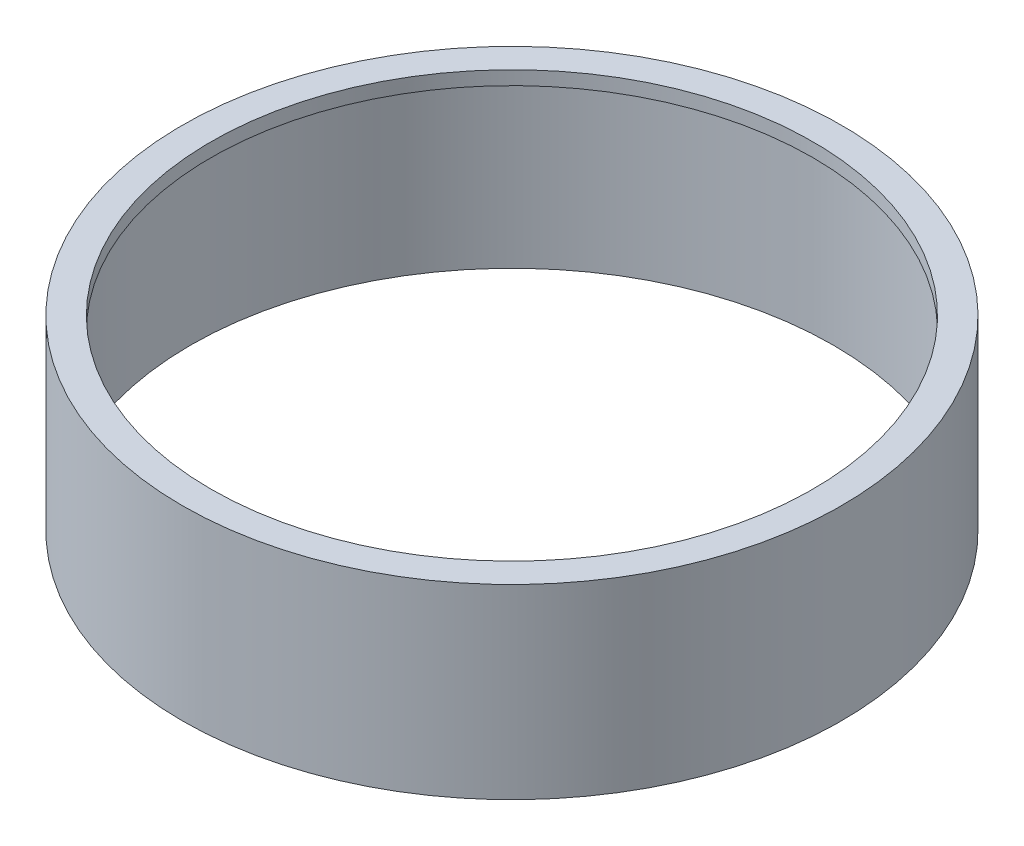
from build123d import *

# Parameters (mm, degrees)
SKETCH1_R           = 40
BOSS_EXTRUDE1_DEPTH = 22.62
SKETCH3_R           = 39
CUT_EXTRUDE1_DEPTH  = 20.95
SKETCH4_R           = 36.525
CUT_EXTRUDE2_DEPTH  = 23.62


with BuildPart() as part:
    # Sketch1 → Boss-Extrude1 (new body)
    with BuildSketch(Plane(origin=(0, 0, 0), x_dir=(1, 0, 0), z_dir=(0, 1, 0))):
        Circle(SKETCH1_R)
    extrude(amount=BOSS_EXTRUDE1_DEPTH)

    # Sketch3 → Cut-Extrude1 (cut)
    with BuildSketch(Plane(origin=(0, 0, 0), x_dir=(-1, 0, 0), z_dir=(0, -1, 0))):
        Circle(SKETCH3_R)
    extrude(amount=-CUT_EXTRUDE1_DEPTH, mode=Mode.SUBTRACT)

    # Sketch4 → Cut-Extrude2 (cut, through all)
    with BuildSketch(Plane(origin=(0, 22.62, 0), x_dir=(1, 0, 0), z_dir=(0, 1, 0))):
        Circle(SKETCH4_R)
    extrude(amount=-CUT_EXTRUDE2_DEPTH, mode=Mode.SUBTRACT)


solid = part.part
